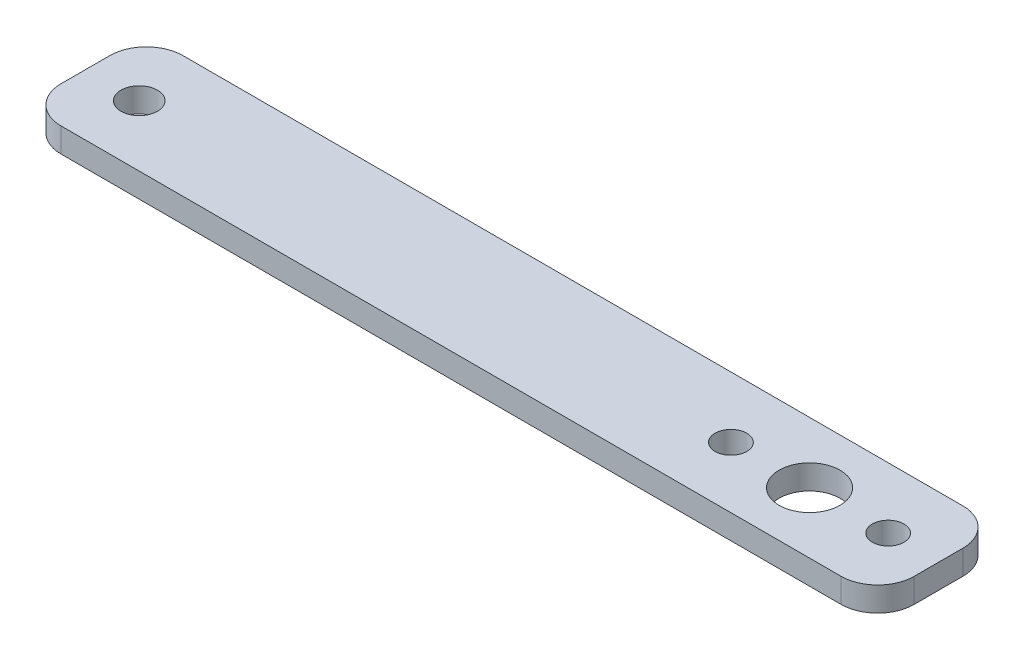
from build123d import *

# Parameters (mm, degrees)
SKETCH1_W             = 70
SKETCH1_H             = 10
BOSS_EXTRUDE1_DEPTH   = 2
F_5_0MM_DOWEL_HOLE1_D = 5
F_3_0MM_DOWEL_HOLE1_D = 3
SKETCH2_R             = 1.3
CUT_EXTRUDE1_DEPTH    = 3
FILLET1_R             = 3


with BuildPart() as part:
    # Sketch1 → Boss-Extrude1 (new body)
    with BuildSketch(Plane(origin=(0, 0, 0), x_dir=(1, 0, 0), z_dir=(0, 1, 0))):
        Rectangle(SKETCH1_W, SKETCH1_H)
    extrude(amount=BOSS_EXTRUDE1_DEPTH)

    # Ø5.0mm Dowel Hole1 (through all)
    with Locations(Plane(origin=(0, 2, 0), x_dir=(1, 0, 0), z_dir=(0, 1, 0))):
        with Locations((24.413883152, 0)):
            Hole(F_5_0MM_DOWEL_HOLE1_D / 2)

    # Ø3.0mm Dowel Hole1 (through all)
    with Locations(Plane(origin=(0, 2, 0), x_dir=(1, 0, 0), z_dir=(0, 1, 0))):
        with Locations((-30.586116848, 0)):
            Hole(F_3_0MM_DOWEL_HOLE1_D / 2)

    # Sketch2 → Cut-Extrude1 (cut)
    with BuildSketch(Plane(origin=(0, 2, 0), x_dir=(1, 0, 0), z_dir=(0, 1, 0))):
        with Locations((30.863883152, 0)):
            Circle(SKETCH2_R)
        with Locations((17.963883152, 0)):
            Circle(SKETCH2_R)
    extrude(amount=-CUT_EXTRUDE1_DEPTH, mode=Mode.SUBTRACT)

    # Fillet1
    fillet1_edges = [part.edges().sort_by_distance(p)[0] for p in [
        (35, 1, 5),
        (-35, 1, 5),
        (-35, 1, -5),
        (35, 1, -5),
    ]]
    fillet(fillet1_edges, radius=FILLET1_R)


solid = part.part
